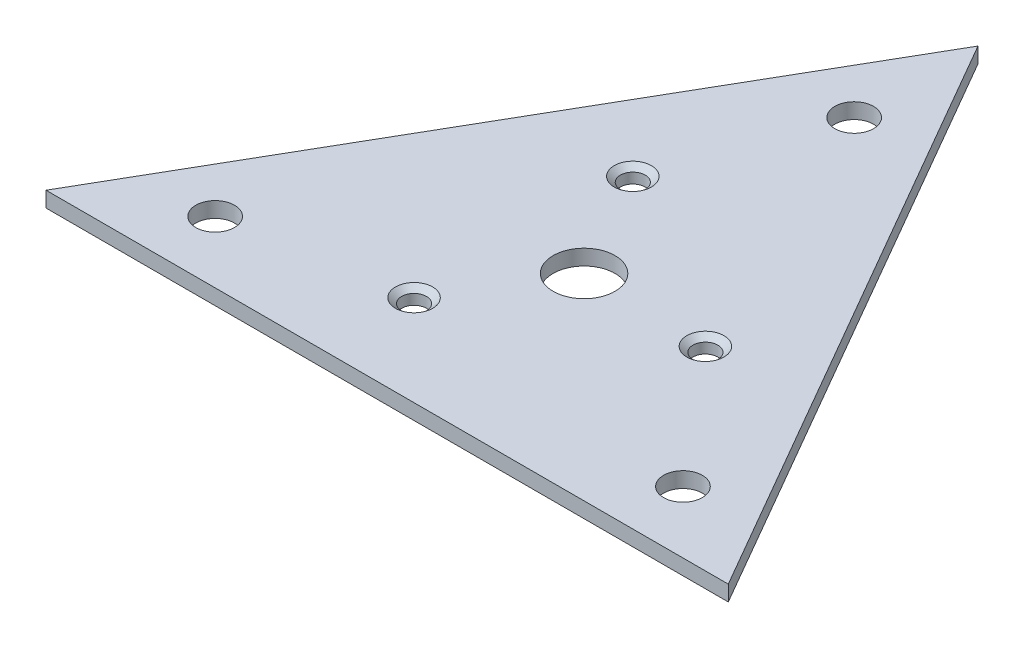
from build123d import *

# Parameters (mm, degrees)
SKETCH1_R                        = 6.35
SKETCH1_R_2                      = 3.96875
BOSS_EXTRUDE1_DEPTH              = 3.175
SKETCH2_R                        = 6.35
CUT_EXTRUDE1_DEPTH               = 0.254
F_1_4_20_TAPPED_HOLE1_AT_2_COUNT = 2
F_1_4_20_TAPPED_HOLE1_AT_2_PITCH = 43.994090512
F_1_4_20_TAPPED_HOLE1_AT_3_COUNT = 2
F_1_4_20_TAPPED_HOLE1_AT_3_PITCH = 43.994090512


with BuildPart() as part:
    # Sketch1 → Boss-Extrude1 (new body)
    with BuildSketch(Plane(origin=(0, 0, 0), x_dir=(1, 0, 0), z_dir=(0, 1, 0))):
        Polygon((0, 0), (139.954, 0), (69.977, 121.203719361), align=None)
        with Locations((69.977, 40.401239787)):
            Circle(SKETCH1_R, mode=Mode.SUBTRACT)
        with Locations((117.956954744, 12.7)):
            Circle(SKETCH1_R_2, mode=Mode.SUBTRACT)
        with Locations((21.997045256, 12.7)):
            Circle(SKETCH1_R_2, mode=Mode.SUBTRACT)
        with Locations((69.977, 95.803719361)):
            Circle(SKETCH1_R_2, mode=Mode.SUBTRACT)
    extrude(amount=BOSS_EXTRUDE1_DEPTH)

    # Sketch2 → Cut-Extrude1 (cut)
    with BuildSketch(Plane(origin=(0, 0, 0), x_dir=(1, 0, 0), z_dir=(0, 1, 0))):
        with Locations((93.966977372, 54.251859681)):
            Circle(SKETCH2_R)
        with Locations((69.977, 12.7)):
            Circle(SKETCH2_R)
        with Locations((45.987022628, 54.251859681)):
            Circle(SKETCH2_R)
    extrude(amount=CUT_EXTRUDE1_DEPTH, mode=Mode.SUBTRACT)

    # Sketch4 → 1/4-20 Tapped Hole1 (revolve, cut)
    with BuildSketch(Plane(origin=(56.837296951, 3.175, -18.663985964), x_dir=(0, 0, 1), z_dir=(1, 0, 0))):
        Polygon((0, 0), (0, 3.175), (2.5527, 3.175), (2.5527, 1.054999966), (3.81, 0), align=None)
    f_1_4_20_tapped_hole1 = revolve(axis=Axis((56.837296951, 9.525, -18.663985964), (0, -1, 0)), mode=Mode.SUBTRACT)

    # 1/4-20 Tapped Hole1 at 2: 1/4-20 Tapped Hole1 ×2
    with Locations(*[Vector(0.875903289, 0, -0.482486712) * (i * F_1_4_20_TAPPED_HOLE1_AT_2_PITCH) for i in range(1, F_1_4_20_TAPPED_HOLE1_AT_2_COUNT)]):
        add(f_1_4_20_tapped_hole1, mode=Mode.SUBTRACT)

    # 1/4-20 Tapped Hole1 at 3: 1/4-20 Tapped Hole1 ×2
    with Locations(*[Vector(0.020105895, 0, -0.999797856) * (i * F_1_4_20_TAPPED_HOLE1_AT_3_PITCH) for i in range(1, F_1_4_20_TAPPED_HOLE1_AT_3_COUNT)]):
        add(f_1_4_20_tapped_hole1, mode=Mode.SUBTRACT)


solid = part.part
